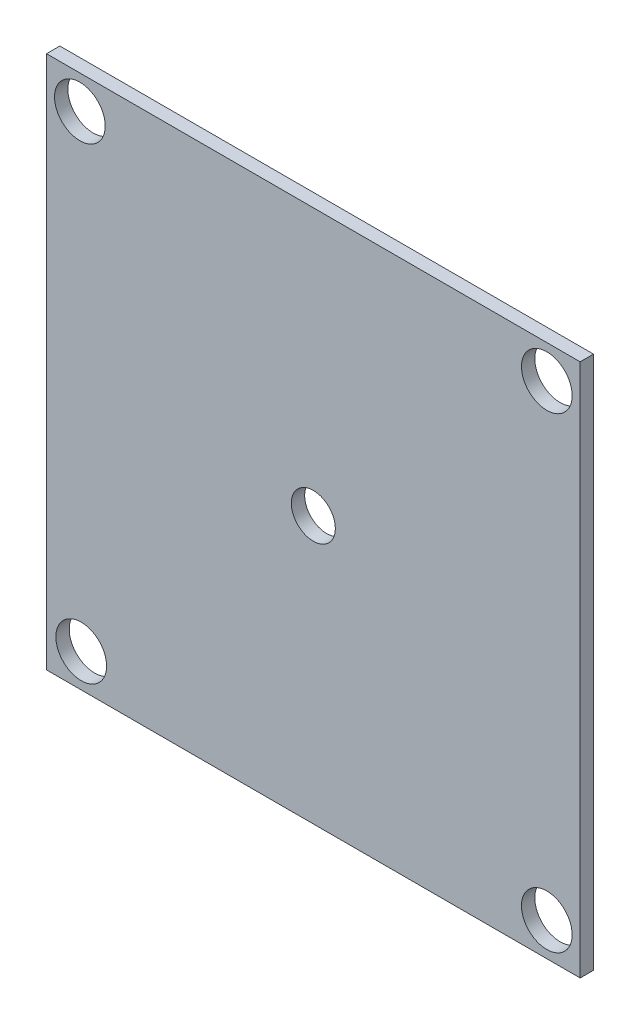
from build123d import *

# Parameters (mm, degrees)
SKETCH1_W           = 101.6
SKETCH1_H           = 101.6
BOSS_EXTRUDE1_DEPTH = 2.54
SKETCH3_R           = 4.191
CUT_EXTRUDE2_DEPTH  = 2.54
SKETCH2_R           = 4.826
CUT_EXTRUDE3_DEPTH  = 2.54


with BuildPart() as part:
    # Sketch1 → Boss-Extrude1 (new body)
    with BuildSketch(Plane.XY):
        Rectangle(SKETCH1_W, SKETCH1_H)
    extrude(amount=BOSS_EXTRUDE1_DEPTH)

    # Sketch3 → Cut-Extrude2 (cut)
    with BuildSketch(Plane.XY.offset(2.54)):
        Circle(SKETCH3_R)
    extrude(amount=-CUT_EXTRUDE2_DEPTH, mode=Mode.SUBTRACT)

    # Sketch2 → Cut-Extrude3 (cut)
    with BuildSketch(Plane.XY.offset(2.54)):
        with Locations((-44.45, 44.45)):
            Circle(SKETCH2_R)
        with Locations((44.45, 44.45)):
            Circle(SKETCH2_R)
        with Locations((44.45, -44.45)):
            Circle(SKETCH2_R)
        with Locations((-44.190779842, -44.45)):
            Circle(SKETCH2_R)
    extrude(amount=-CUT_EXTRUDE3_DEPTH, mode=Mode.SUBTRACT)


solid = part.part
